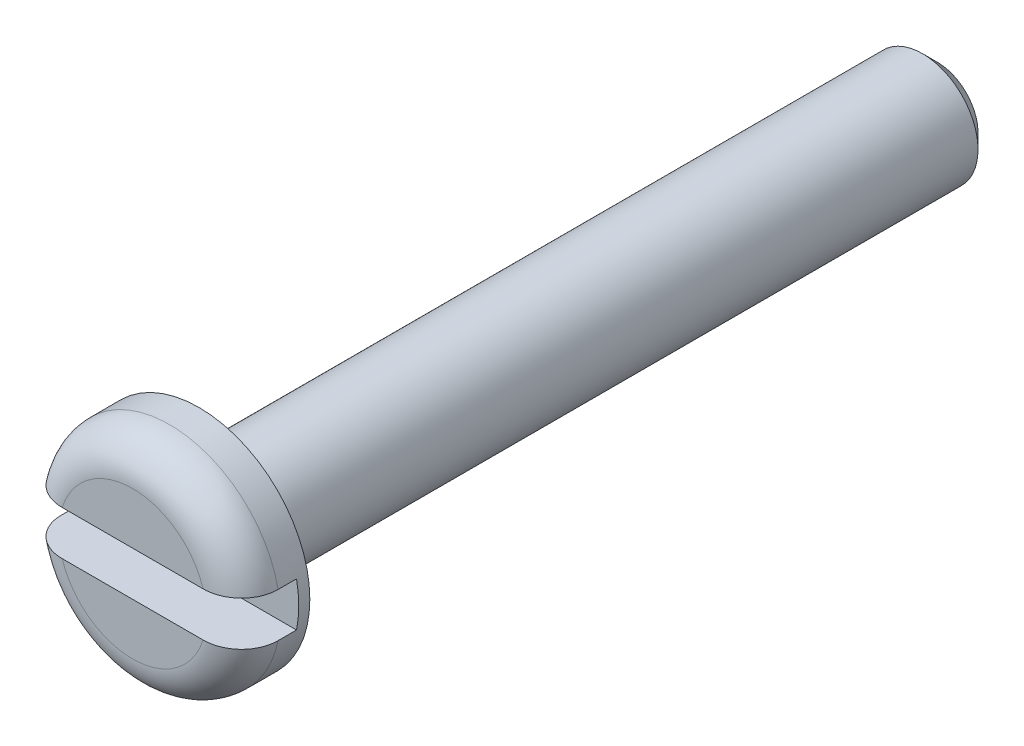
from build123d import *

# Parameters (mm, degrees)
SKETCH_2_W               = 1.5
SKETCH_2_H               = 1.2
CUT_EXTRUDE_1_DEPTH      = 4
CUT_EXTRUDE_1_DEPTH_BACK = 4
CHAMFER_1_SIZE           = 0.4
FILLET_1_R               = 1
FILLET_2_R               = 0.4


with BuildPart() as part:
    # Эскиз1 → Повернуть1 (revolve)
    with BuildSketch(Plane(origin=(0, 0, 0), x_dir=(1, 0, 0), z_dir=(0, 1, 0))):
        Polygon((0, 0), (-3, 0), (-3, 1.8), (-1.5, 1.8), (-1.5, 21.8), (0, 21.8), align=None)
    revolve(axis=Axis((0, 0, -21.8), (0, 0, 1)))

    # Эскиз2 → Вырез-Вытянуть1 (cut, two sides)
    with BuildSketch(Plane(origin=(0, 0, 0), x_dir=(0, 0, -1), z_dir=(1, 0, 0))) as cut_extrude_1_sk:
        with Locations((0.75, 0)):
            Rectangle(SKETCH_2_W, SKETCH_2_H)
    extrude(amount=CUT_EXTRUDE_1_DEPTH, mode=Mode.SUBTRACT)
    extrude(cut_extrude_1_sk.sketch, amount=-CUT_EXTRUDE_1_DEPTH_BACK, mode=Mode.SUBTRACT)

    # Фаска1
    chamfer_1_edges = [part.edges().sort_by_distance(p)[0] for p in [
        (1.5, 0, -21.8),
    ]]
    chamfer(chamfer_1_edges, length=CHAMFER_1_SIZE)

    # Скругление1
    fillet_1_edges = [part.edges().sort_by_distance(p)[0] for p in [
        (0, 3, 0),
        (0, -3, 0),
    ]]
    fillet(fillet_1_edges, radius=FILLET_1_R)

    # Скругление2
    fillet_2_edges = [part.edges().sort_by_distance(p)[0] for p in [
        (1.5, 0, -1.8),
    ]]
    fillet(fillet_2_edges, radius=FILLET_2_R)


solid = part.part
